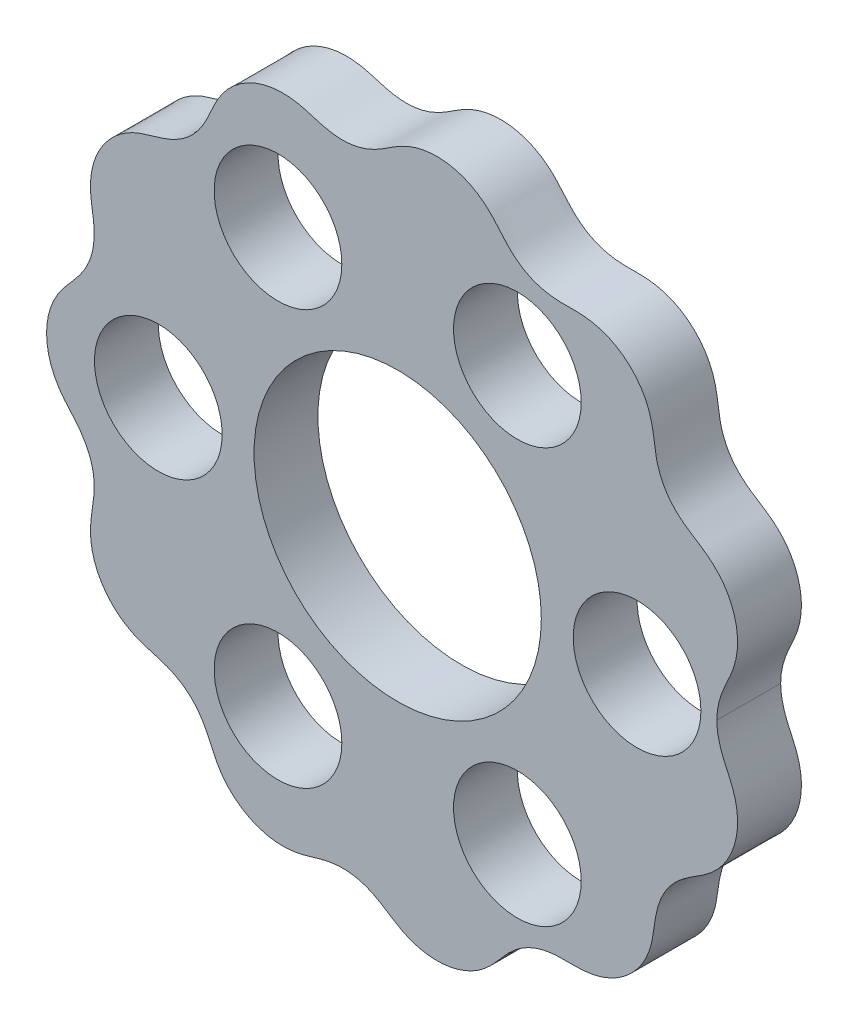
from build123d import *

# Parameters (mm, degrees)
MAIN_PROFILE_DEPTH = 6.35
SKETCH4_R          = 14.2875
SKETCH4_R_2        = 6.35
CUT_EXTRUDE1_DEPTH = 50.602386466


with BuildPart() as part:
    # Sketch3 → Main Profile (new body)
    with BuildSketch(Plane.XY):
        with BuildLine():
            add(Edge.make_bspline(
                [(31.75, 2.81e-07), (31.75, -0.038138771), (31.750810332, -0.114368264), (31.753849076, -0.238837626), (31.760525509, -0.382455818), (31.769615286, -0.519564523), (31.781109533, -0.652336128), (31.798002594, -0.807740925), (31.822028132, -0.986734635), (31.850700016, -1.164686809), (31.897846423, -1.415637564), (31.971645203, -1.738301952), (32.082469268, -2.129360193), (32.240686958, -2.584508221), (32.435705321, -3.067108271), (32.665594027, -3.576923413), (32.921307313, -4.117284729), (33.181296154, -4.69866334), (33.481203305, -5.481075034), (33.747908546, -6.487838935), (33.871349627, -7.728759397), (33.73330509, -9.164623802), (33.326541508, -10.541721209), (32.669757062, -11.811709211), (31.818024493, -12.88839187), (30.823627825, -13.758045179), (29.803850972, -14.41160519), (28.863124943, -14.991909497), (27.938459683, -15.6906083), (27.086683665, -16.552965023), (26.431573246, -17.535822666), (25.984740003, -18.585398338), (25.695291585, -19.66213801), (25.529158833, -20.739291715), (25.392052795, -21.96040977), (25.05590048, -23.293979323), (24.466833712, -24.564227673), (23.632299814, -25.717648459), (22.595789884, -26.69262707), (21.394063242, -27.456498992), (19.915003335, -28.038283816), (18.396820055, -28.272115609), (16.936938439, -28.214152446), (15.476800928, -28.242612595), (14.193614192, -28.458701253), (12.897903092, -28.948399701), (11.68795127, -29.742785535), (10.662699935, -30.756784477), (9.870854151, -31.74993016), (9.129360193, -32.545471996), (8.298351028, -33.246351695), (7.382345444, -33.835876138), (6.227792799, -34.33504204), (4.838281693, -34.643712395), (3.415691487, -34.685747804), (2.138585694, -34.479135678), (1.041108058, -34.101813017), (0.029840997, -33.589918692), (-0.895830501, -32.984865294), (-1.924155018, -32.299593481), (-3.162011496, -31.707982495), (-4.519359583, -31.361868513), (-5.919373076, -31.315778501), (-7.273101382, -31.53820905), (-8.452285877, -31.907514482), (-9.511416844, -32.225815349), (-10.626457936, -32.429340195), (-11.785928621, -32.479028469), (-13.069065379, -32.31398879), (-14.421002475, -31.869258957), (-15.665432525, -31.178298164), (-16.630410555, -30.371469197), (-17.340974789, -29.545808367), (-17.938508363, -28.637678251), (-18.423824728, -27.664482285), (-18.897692439, -26.50412342), (-19.588777128, -25.257453018), (-20.509978823, -24.164402668), (-21.818254492, -23.162120116), (-23.502291231, -22.43899478), (-25.286536347, -22.087593132), (-26.954516172, -21.326501044), (-28.228521063, -20.348660606), (-29.173358892, -19.283427555), (-29.900550559, -18.060159424), (-30.384876126, -16.721491378), (-30.602129294, -15.329819453), (-30.554794927, -13.938323222), (-30.338343583, -12.711785587), (-30.192247227, -11.614870091), (-30.16936859, -10.491818606), (-30.30554933, -9.35912283), (-30.660892747, -8.232912318), (-31.237897787, -7.166687652), (-31.839984981, -6.360069652), (-32.365507449, -5.753873672), (-32.832998588, -5.226851201), (-33.223046034, -4.761998387), (-33.601608275, -4.255506716), (-33.954091311, -3.700186252), (-34.227037244, -3.171797098), (-34.432331805, -2.682131162), (-34.576895351, -2.26401638), (-34.676384382, -1.924619974), (-34.759527034, -1.580268144), (-34.826183466, -1.233483302), (-34.869996832, -0.925784539), (-34.897142003, -0.662631599), (-34.912809999, -0.44544961), (-34.921168461, -0.258331289), (-34.924303367, -0.112395088), (-34.925000006, -0.037463791), (-34.925, 1.553e-06)],
                knots=[0.076222728, 0.076222728, 0.076222728, 0.076222728, 0.076222728, 0.07758073, 0.078938736, 0.079617739, 0.080296742, 0.081654748, 0.083012754, 0.08437076, 0.085728767, 0.087086773, 0.090719289, 0.094351805, 0.097984321, 0.101616837, 0.106418748, 0.111220659, 0.11602257, 0.120824481, 0.131683243, 0.14254258, 0.153401614, 0.164073767, 0.174745748, 0.18541611, 0.19456768, 0.203719251, 0.211244993, 0.218770735, 0.229447575, 0.240126118, 0.246585424, 0.25304473, 0.263011351, 0.272977971, 0.283649723, 0.294321301, 0.304993174, 0.315665052, 0.326337359, 0.337009019, 0.352677248, 0.361519663, 0.370362078, 0.381038411, 0.391712234, 0.403003621, 0.413672245, 0.424340869, 0.430041507, 0.435742145, 0.446413419, 0.45708552, 0.467757287, 0.478429952, 0.489101139, 0.495868465, 0.502635792, 0.512543347, 0.522450902, 0.5331287, 0.543806945, 0.554484724, 0.56439215, 0.574299576, 0.581066916, 0.587834256, 0.598505429, 0.60917809, 0.619849863, 0.63052197, 0.641193252, 0.646893867, 0.652594483, 0.663262993, 0.673931502, 0.684719378, 0.69539681, 0.706070852, 0.72325738, 0.739426165, 0.750097519, 0.760769201, 0.771441421, 0.782113164, 0.792785707, 0.803455743, 0.813673144, 0.823890545, 0.830349968, 0.836809391, 0.847487966, 0.85816375, 0.865689926, 0.873216103, 0.877791873, 0.882367644, 0.886943414, 0.891519184, 0.896854416, 0.902189647, 0.90485764, 0.907525634, 0.910193627, 0.91286162, 0.915529656, 0.918197691, 0.919531708, 0.920865726, 0.922199744, 0.923533734, 0.923533734, 0.923533734, 0.923533734, 0.923533734], degree=4))
            add(Edge.make_bspline(
                [(31.75, 2.81e-07), (31.750000001, 0.038139052), (31.750810334, 0.114368545), (31.75384908, 0.238837908), (31.760525516, 0.382456099), (31.769615296, 0.519564804), (31.781109545, 0.652336409), (31.798002609, 0.807741205), (31.822028151, 0.986734915), (31.850700038, 1.164687089), (31.89784645, 1.415637843), (31.971645236, 1.738302229), (32.082469308, 2.129360468), (32.240687007, 2.584508493), (32.43570538, 3.067108539), (32.665594095, 3.576923677), (32.921307392, 4.117284988), (33.181296243, 4.698663594), (33.48120341, 5.481075282), (33.74790867, 6.487839178), (33.871349774, 7.728759638), (33.733305265, 9.164624045), (33.326541709, 10.54172146), (32.669757288, 11.811709475), (31.818024739, 12.88839215), (30.823628087, 13.758045478), (29.803851247, 14.411605508), (28.863125229, 14.991909833), (27.938459982, 15.690608654), (27.08668398, 16.552965393), (26.431573581, 17.535823048), (25.984740357, 18.585398729), (25.69529196, 19.662138407), (25.529159228, 20.739292115), (25.392053214, 21.960410173), (25.055900924, 23.293979732), (24.46683418, 24.564228093), (23.632300305, 25.717648895), (22.595790393, 26.692627526), (21.394063766, 27.456499471), (19.91500387, 28.038284323), (18.396820594, 28.272116145), (16.936938977, 28.21415301), (15.476801466, 28.242613187), (14.193614735, 28.458701869), (12.897903644, 28.948400341), (11.687951838, 29.742786198), (10.662700522, 30.75678516), (9.870854756, 31.749930858), (9.129360813, 32.545472708), (8.298351662, 33.246352424), (7.38234609, 33.835876884), (6.227793453, 34.335042808), (4.838282354, 34.64371319), (3.415692149, 34.685748626), (2.138586351, 34.479136524), (1.041108709, 34.101813884), (0.029841637, 33.589919578), (-0.895829872, 32.984866197), (-1.924154402, 32.299594404), (-3.162010891, 31.707983442), (-4.519358985, 31.361869486), (-5.919372479, 31.315779501), (-7.27310078, 31.538210075), (-8.452285269, 31.90751553), (-9.51141623, 32.225816417), (-10.626457318, 32.429341284), (-11.785928001, 32.47902958), (-13.069064763, 32.313989926), (-14.421001867, 31.869260118), (-15.665431931, 31.178299349), (-16.630409975, 30.371470401), (-17.340974225, 29.545809584), (-17.938507817, 28.637679479), (-18.4238242, 27.664483523), (-18.897691934, 26.504124667), (-19.588776647, 25.257454278), (-20.509978362, 24.164403946), (-21.81825405, 23.162121419), (-23.502290803, 22.438996115), (-25.286535925, 22.087594501), (-26.954515766, 21.326502445), (-28.228520675, 20.348662031), (-29.173358524, 19.283428998), (-29.900550215, 18.060160881), (-30.384875808, 16.721492844), (-30.602129002, 15.329820923), (-30.554794662, 13.938324691), (-30.338343341, 12.711787052), (-30.192247005, 11.614871553), (-30.16936839, 10.491820068), (-30.305549151, 9.359124294), (-30.66089259, 8.232913789), (-31.23789765, 7.166689135), (-31.83998486, 6.360071146), (-32.36550734, 5.753875176), (-32.832998489, 5.226852714), (-33.223045943, 4.761999907), (-33.601608193, 4.255508244), (-33.954091241, 3.700187786), (-34.227037183, 3.171798638), (-34.432331754, 2.682132705), (-34.576895308, 2.264017926), (-34.676384346, 1.924621522), (-34.759527004, 1.580269694), (-34.826183443, 1.233484853), (-34.869996815, 0.925786091), (-34.89714199, 0.662633151), (-34.912809991, 0.445451162), (-34.921168456, 0.258332842), (-34.924303365, 0.112396641), (-34.925000006, 0.037465344), (-34.925, 1.553e-06)],
                knots=[0.076222723, 0.076222723, 0.076222723, 0.076222723, 0.076222723, 0.07758073, 0.078938736, 0.079617739, 0.080296742, 0.081654748, 0.083012754, 0.08437076, 0.085728767, 0.087086773, 0.090719289, 0.094351805, 0.097984321, 0.101616837, 0.106418748, 0.111220659, 0.11602257, 0.120824481, 0.131683243, 0.14254258, 0.153401614, 0.164073767, 0.174745748, 0.18541611, 0.19456768, 0.203719251, 0.211244993, 0.218770735, 0.229447575, 0.240126118, 0.246585424, 0.25304473, 0.263011351, 0.272977971, 0.283649723, 0.294321301, 0.304993174, 0.315665052, 0.326337359, 0.337009019, 0.352677248, 0.361519663, 0.370362078, 0.381038411, 0.391712234, 0.403003621, 0.413672245, 0.424340869, 0.430041507, 0.435742145, 0.446413419, 0.45708552, 0.467757287, 0.478429952, 0.489101139, 0.495868465, 0.502635792, 0.512543347, 0.522450902, 0.5331287, 0.543806945, 0.554484724, 0.56439215, 0.574299576, 0.581066916, 0.587834256, 0.598505429, 0.60917809, 0.619849863, 0.63052197, 0.641193252, 0.646893867, 0.652594483, 0.663262993, 0.673931502, 0.684719378, 0.69539681, 0.706070852, 0.72325738, 0.739426165, 0.750097519, 0.760769201, 0.771441421, 0.782113164, 0.792785707, 0.803455743, 0.813673144, 0.823890545, 0.830349968, 0.836809391, 0.847487966, 0.85816375, 0.865689926, 0.873216103, 0.877791873, 0.882367644, 0.886943414, 0.891519184, 0.896854416, 0.902189647, 0.90485764, 0.907525634, 0.910193627, 0.91286162, 0.915529656, 0.918197691, 0.919531708, 0.920865726, 0.922199744, 0.923533739, 0.923533739, 0.923533739, 0.923533739, 0.923533739], degree=4))
        make_face()
    extrude(amount=MAIN_PROFILE_DEPTH)

    # Sketch4 → Cut-Extrude1 (cut, through all)
    with BuildSketch(Plane.XY.offset(6.35)):
        Circle(SKETCH4_R)
        with Locations((-23.8125, 0)):
            Circle(SKETCH4_R_2)
        with Locations((-11.90625, 20.622229928)):
            Circle(SKETCH4_R_2)
        with Locations((11.90625, 20.622229928)):
            Circle(SKETCH4_R_2)
        with Locations((23.8125, 0)):
            Circle(SKETCH4_R_2)
        with Locations((11.90625, -20.622229928)):
            Circle(SKETCH4_R_2)
        with Locations((-11.90625, -20.622229928)):
            Circle(SKETCH4_R_2)
    extrude(amount=-CUT_EXTRUDE1_DEPTH, mode=Mode.SUBTRACT)


solid = part.part
